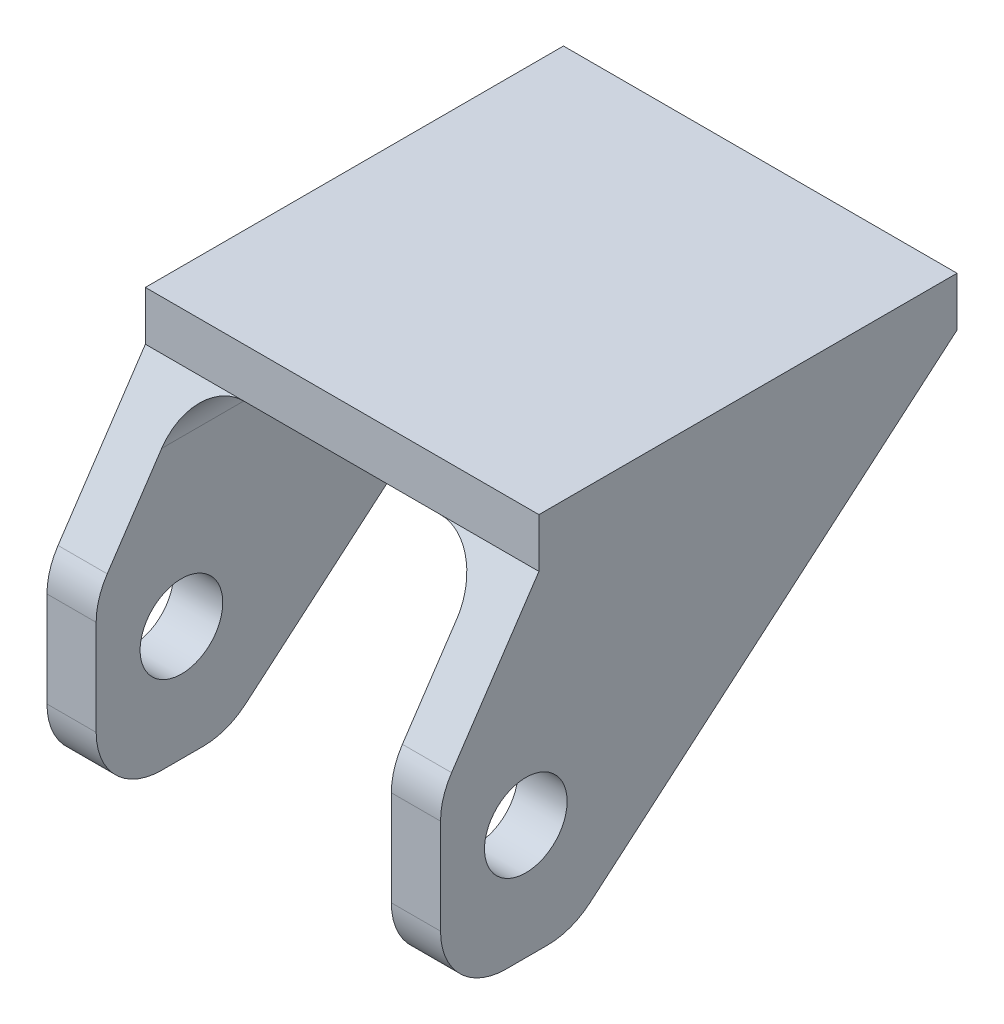
from build123d import *

# Parameters (mm, degrees)
SKETCH1_W           = 4.7625
SKETCH1_H           = 50
SKETCH1_W_2         = 28.575
BOSS_EXTRUDE1_DEPTH = 4.7625
SKETCH1_3_W         = 4.7625
SKETCH1_3_H         = 50
BOSS_EXTRUDE2_DEPTH = 31.75
SKETCH3_R           = 4
CUT_EXTRUDE1_DEPTH  = 39.1
FILLET1_R           = 6.35
FILLET2_R           = 4.7625


with BuildPart() as part:
    # Sketch1 → Boss-Extrude1 (new body)
    with BuildSketch(Plane(origin=(0, 0, 0), x_dir=(1, 0, 0), z_dir=(0, 1, 0))):
        with Locations((-16.66875, 0)):
            Rectangle(SKETCH1_W, SKETCH1_H)
        Rectangle(SKETCH1_W_2, SKETCH1_H)
        with Locations((16.66875, 0)):
            Rectangle(SKETCH1_W, SKETCH1_H)
    extrude(amount=BOSS_EXTRUDE1_DEPTH)

    # Sketch1_3 → Boss-Extrude2 (add)
    with BuildSketch(Plane(origin=(0, 0, 0), x_dir=(1, 0, 0), z_dir=(0, 1, 0))):
        with Locations((-16.66875, 0)):
            Rectangle(SKETCH1_3_W, SKETCH1_3_H)
        with Locations((16.66875, 0)):
            Rectangle(SKETCH1_3_W, SKETCH1_3_H)
    extrude(amount=-BOSS_EXTRUDE2_DEPTH)

    # Sketch3 → Cut-Extrude1 (cut, through all)
    with BuildSketch(Plane(origin=(19.05, 0, 0), x_dir=(0, 0, -1), z_dir=(1, 0, 0))):
        Polygon((25, -31.75), (25, 0), (-12.3, -31.75), align=None)
        Polygon((-15.475, 0), (-15.475, 4.7625), (-25, 4.7625), (-25, 0), (-25, -14.247596398), align=None)
        with Locations((-16.745, -20.6375)):
            Circle(SKETCH3_R)
    extrude(amount=-CUT_EXTRUDE1_DEPTH, mode=Mode.SUBTRACT)

    # Fillet1
    fillet1_edges = [part.edges().sort_by_distance(p)[0] for p in [
        (-16.66875, -31.75, 25),
        (16.66875, -31.75, 25),
        (16.66875, -31.75, 12.3),
        (-16.66875, -31.75, 12.3),
        (16.66875, -14.247596398, 25),
        (-16.66875, -14.247596398, 25),
    ]]
    fillet(fillet1_edges, radius=FILLET1_R)

    # Fillet2
    fillet2_edges = [part.edges().sort_by_distance(p)[0] for p in [
        (14.2875, 0, -4.7625),
        (-14.2875, 0, -4.7625),
    ]]
    fillet(fillet2_edges, radius=FILLET2_R)


solid = part.part
